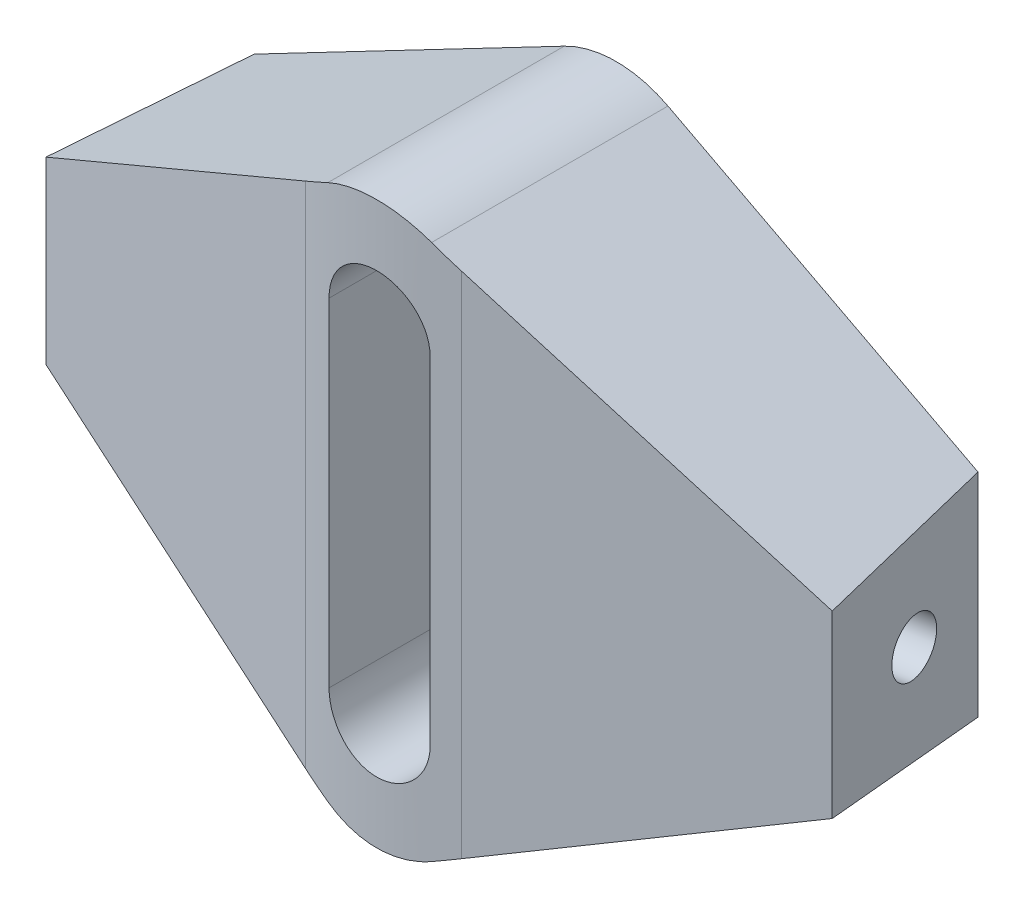
from build123d import *

# Parameters (mm, degrees)
AUFSATZ_LINEAR_AUSTRAGEN3_DEPTH      = 20
SCHNITT_LINEAR_AUSTRAGEN9_DEPTH      = 30.368350311
SCHNITT_LINEAR_AUSTRAGEN9_DEPTH_BACK = 30.368350311
SKIZZE10_OUTSIDE_W                   = 46.486
SKIZZE10_OUTSIDE_H                   = 31.486
SKIZZE7_R                            = 1.23
SCHNITT_LINEAR_AUSTRAGEN8_DEPTH      = 12


with BuildPart() as part:
    # Skizze3 → Aufsatz-Linear austragen3 (new body)
    with BuildSketch(Plane.XY):
        with BuildLine():
            Line((-2.308809744, 11.933429348), (-17.5, 4))
            Line((-17.5, 4), (-17.5, -4))
            Line((-17.5, -4), (-2.308809744, -11.933429348))
            ThreePointArc((-2.308809744, -11.933429348), (0, -12.5), (2.308809744, -11.933429348))
            Line((2.308809744, -11.933429348), (17.5, -4))
            Line((17.5, -4), (17.5, 4))
            Line((17.5, 4), (2.308809744, 11.933429348))
            ThreePointArc((2.308809744, 11.933429348), (0, 12.5), (-2.308809744, 11.933429348))
        make_face()
        with BuildLine():
            ThreePointArc((2.25, -7.51244486), (0, -9.76244486), (-2.25, -7.51244486))
            Line((-2.25, -7.51244486), (-2.25, 7.51244486))
            ThreePointArc((-2.25, 7.51244486), (0, 9.76244486), (2.25, 7.51244486))
            Line((2.25, 7.51244486), (2.25, -7.51244486))
        make_face(mode=Mode.SUBTRACT)
    extrude(amount=AUFSATZ_LINEAR_AUSTRAGEN3_DEPTH)

    # Skizze10 outside → Schnitt-Linear austragen9 (cut, two sides: drawn at the far end of the back side and taken through both)
    with BuildSketch(Plane(origin=(0, 0, 0), x_dir=(1, 0, 0), z_dir=(0, 1, 0)).offset(-SCHNITT_LINEAR_AUSTRAGEN9_DEPTH_BACK)):
        with Locations((0, -10)):
            Rectangle(SKIZZE10_OUTSIDE_W, SKIZZE10_OUTSIDE_H)
        with BuildLine():
            Line((-16.110814579, 0), (-17.5, -7.878462024))
            Line((-17.5, -7.878462024), (-3.472963553, -10.351807009))
            ThreePointArc((-3.472963553, -10.351807009), (0, -10.655651949), (3.472963553, -10.351807009))
            Line((3.472963553, -10.351807009), (17.5, -7.878462024))
            Line((17.5, -7.878462024), (16.110814579, 0))
            Line((16.110814579, 0), (-16.110814579, 0))
        make_face(mode=Mode.SUBTRACT)
    extrude(amount=SCHNITT_LINEAR_AUSTRAGEN9_DEPTH + SCHNITT_LINEAR_AUSTRAGEN9_DEPTH_BACK, mode=Mode.SUBTRACT)

    # Skizze7 → Schnitt-Linear austragen8 (cut)
    with BuildSketch(Plane(origin=(-16.983254832, 0, 4.947854546), x_dir=(-0.17364817766692744, 0, 0.9848077530122087), z_dir=(-0.9848077530122087, 0, -0.17364817766692744))):
        with Locations((-1.524183177, 0)):
            Circle(SKIZZE7_R)
    schnitt_linear_austragen8 = extrude(amount=-SCHNITT_LINEAR_AUSTRAGEN8_DEPTH, mode=Mode.SUBTRACT)

    # Spiegeln4: Schnitt-Linear austragen8 across plane
    add(schnitt_linear_austragen8.mirror(Plane(origin=(0, 0, 0), x_dir=(0, 0, 1), z_dir=(1, 0, 0))), mode=Mode.SUBTRACT)


solid = part.part
